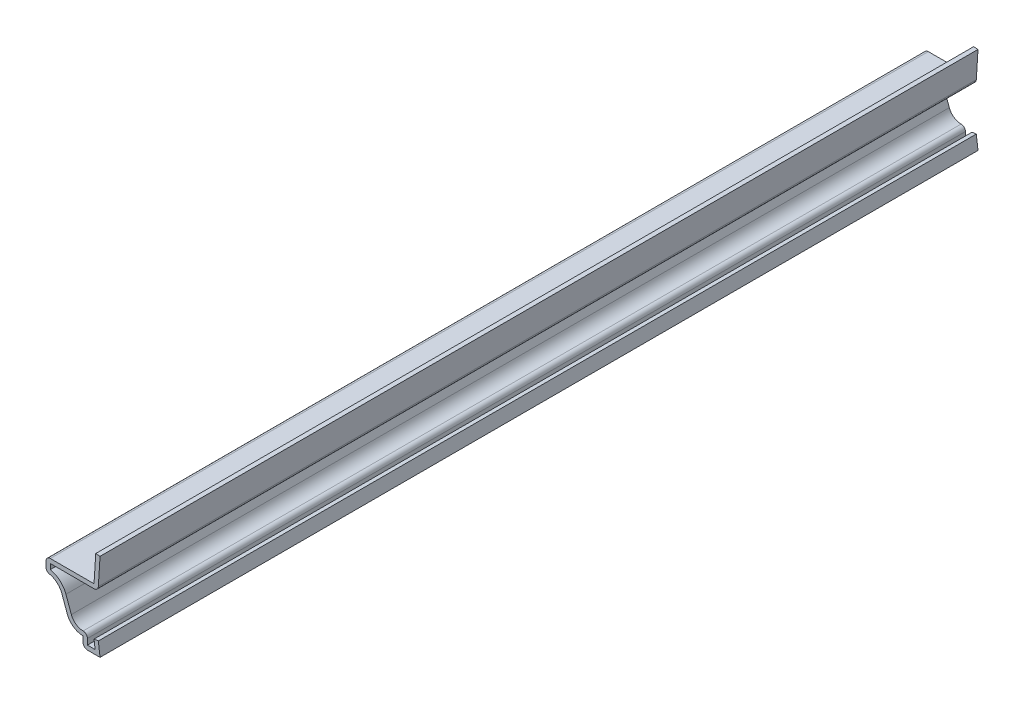
from build123d import *

# Parameters (mm, degrees)
EXTRUDE_THIN1_DEPTH = 206.375
FILLET1_R           = 1.016


with BuildPart() as part:
    # Sketch1 → Extrude-Thin1 (new body)
    with BuildSketch(Plane.XY):
        with BuildLine():
            Line((-1.01402142, 20.6375), (-1.41089642, 14.2875))
            Line((-1.41089642, 14.2875), (-12.7, 14.2875))
            Line((-12.7, 14.2875), (-12.7, 11.1125))
            ThreePointArc((-12.7, 11.1125), (-10.421749313, 10.393450043), (-8.969036168, 8.496852156))
            Line((-8.969036168, 8.496852156), (-7.699713832, 4.996897844))
            ThreePointArc((-7.699713832, 4.996897844), (-6.247000687, 3.100299957), (-3.96875, 2.38125))
            Line((-3.96875, 2.38125), (-3.96875, 0))
            Line((-3.96875, 0), (0, 0))
            Line((0, 0), (-0.396875, 3.150097655))
            Line((-0.396875, 3.150097655), (-1.40490625, 3.023097655))
            Line((-1.40490625, 3.023097655), (-1.152035714, 1.016))
            Line((-1.152035714, 1.016), (-2.95275, 1.016))
            Line((-2.95275, 1.016), (-2.95275, 3.57755044))
            ThreePointArc((-2.95275, 3.57755044), (-5.215232033, 3.673245416), (-6.744587091, 5.343291996))
            Line((-6.744587091, 5.343291996), (-8.013909427, 8.843246308))
            ThreePointArc((-8.013909427, 8.843246308), (-9.435411883, 10.910737787), (-11.684, 12.023860302))
            Line((-11.684, 12.023860302), (-11.684, 13.2715))
            Line((-11.684, 13.2715), (-0.456413979, 13.2715))
            Line((-0.456413979, 13.2715), (0, 20.574123661))
            Line((0, 20.574123661), (-1.01402142, 20.6375))
        make_face()
    extrude(amount=-EXTRUDE_THIN1_DEPTH)

    # Fillet1
    fillet1_edges = [part.edges().sort_by_distance(p)[0] for p in [
        (-3.96875, 0, -103.1875),
        (-12.7, 11.1125, -103.1875),
        (-12.7, 14.2875, -103.1875),
        (-0.456413979, 13.2715, -103.1875),
        (-2.95275, 3.57755044, -103.1875),
    ]]
    fillet(fillet1_edges, radius=FILLET1_R)


solid = part.part
